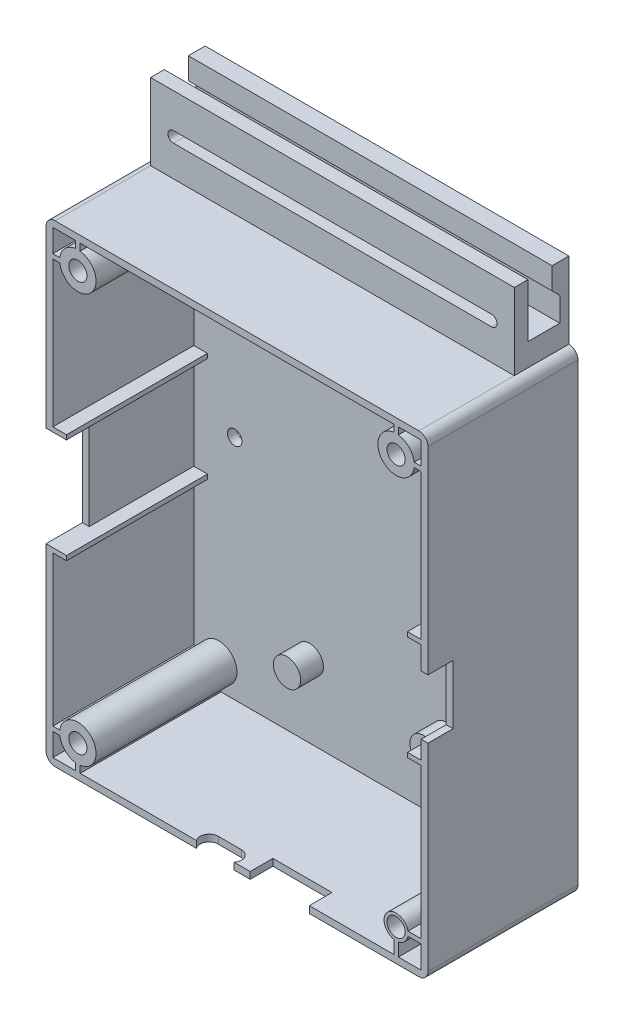
from build123d import *

# Parameters (mm, degrees)
SKETCH_2_R          = 2
EXTRUDE_1_DEPTH     = 31
EXTRUDE_1_2_DEPTH   = 31
EXTRUDE_1_3_DEPTH   = 31
EXTRUDE_1_4_DEPTH   = 31
SKETCH_3_W          = 81
SKETCH_3_H          = 101
EXTRUDE_2_DEPTH     = 31
EXTRUDE_3_DEPTH     = 2
CUT_EXTRUDE_1_REACH = 86
SKETCH_5_W          = 8
SKETCH_5_H          = 22
CUT_EXTRUDE_2_REACH = 86
SKETCH_6_W          = 5.5
SKETCH_6_H          = 13
CUT_EXTRUDE_3_REACH = 106
SKETCH_7_W          = 13
SKETCH_7_H          = 5
SKETCH_8_R          = 3
EXTRUDE_4_DEPTH     = 5
SKETCH_9_R          = 2
CUT_EXTRUDE_4_DEPTH = 5
SKETCH_10_W         = 80
SKETCH_10_H         = 12
EXTRUDE_5_DEPTH     = 5
SKETCH_11_W         = 3
SKETCH_11_H         = 11.8
EXTRUDE_6_DEPTH     = 80
CUT_EXTRUDE_5_DEPTH = 3
SKETCH_13_R         = 1.6
CUT_EXTRUDE_6_DEPTH = 3
SKETCH_14_W         = 31
SKETCH_14_H         = 1
EXTRUDE_7_DEPTH     = 3
SKETCH_15_W         = 31
SKETCH_15_H         = 1
EXTRUDE_8_DEPTH     = 3


with BuildPart() as part:
    # 草图2 → 凸台-拉伸1 (new body)
    with BuildSketch(Plane.XY):
        with BuildLine():
            Line((-38.968626967, -45.5), (-40.968626967, -45.5))
            Line((-40.968626967, -45.5), (-40.968626967, -44.5))
            Line((-40.968626967, -44.5), (-38.968626967, -44.5))
            ThreePointArc((-38.968626967, -44.5), (-32.171572875, -42.171572875), (-34.5, -48.968626967))
            Line((-34.5, -48.968626967), (-34.5, -50.968626967))
            Line((-34.5, -50.968626967), (-35.5, -50.968626967))
            Line((-35.5, -50.968626967), (-35.5, -48.968626967))
            ThreePointArc((-35.5, -48.968626967), (-37.828427125, -47.828427125), (-38.968626967, -45.5))
        make_face()
        with Locations((-35, -45)):
            Circle(SKETCH_2_R, mode=Mode.SUBTRACT)
    extrude(amount=-EXTRUDE_1_DEPTH)



with BuildPart() as body_2:
    # 草图2 → Extrude 1 2 (new body)
    with BuildSketch(Plane.XY):
        with BuildLine():
            Line((-35.5, 50.968626967), (-34.5, 50.968626967))
            Line((-34.5, 50.968626967), (-34.5, 48.968626967))
            ThreePointArc((-34.5, 48.968626967), (-32.171572875, 42.171572875), (-38.968626967, 44.5))
            Line((-38.968626967, 44.5), (-40.968626967, 44.5))
            Line((-40.968626967, 44.5), (-40.968626967, 45.5))
            Line((-40.968626967, 45.5), (-38.968626967, 45.5))
            ThreePointArc((-38.968626967, 45.5), (-37.828427125, 47.828427125), (-35.5, 48.968626967))
            Line((-35.5, 48.968626967), (-35.5, 50.968626967))
        make_face()
        with Locations((-35, 45)):
            Circle(SKETCH_2_R, mode=Mode.SUBTRACT)
    extrude(amount=-EXTRUDE_1_2_DEPTH)


with BuildPart() as body_3:
    # 草图2 → Extrude 1 3 (new body)
    with BuildSketch(Plane.XY):
        with BuildLine():
            Line((34.5, 50.968626967), (35.5, 50.968626967))
            Line((35.5, 50.968626967), (35.5, 48.968626967))
            ThreePointArc((35.5, 48.968626967), (37.828427125, 47.828427125), (38.968626967, 45.5))
            Line((38.968626967, 45.5), (40.968626967, 45.5))
            Line((40.968626967, 45.5), (40.968626967, 44.5))
            Line((40.968626967, 44.5), (38.968626967, 44.5))
            ThreePointArc((38.968626967, 44.5), (32.171572875, 42.171572875), (34.5, 48.968626967))
            Line((34.5, 48.968626967), (34.5, 50.968626967))
        make_face()
        with Locations((35, 45)):
            Circle(SKETCH_2_R, mode=Mode.SUBTRACT)
    extrude(amount=-EXTRUDE_1_3_DEPTH)


with BuildPart() as body_4:
    # 草图2 → Extrude 1 4 (new body)
    with BuildSketch(Plane.XY):
        with BuildLine():
            Line((40.602402736, -44.5), (40.602402736, -45.5))
            Line((40.602402736, -45.5), (37.602402736, -45.5))
            ThreePointArc((37.602402736, -45.5), (36.87383297, -46.87383297), (35.5, -47.602402736))
            Line((35.5, -47.602402736), (35.5, -50.602402736))
            Line((35.5, -50.602402736), (34.5, -50.602402736))
            Line((34.5, -50.602402736), (34.5, -47.602402736))
            ThreePointArc((34.5, -47.602402736), (33.12616703, -43.12616703), (37.602402736, -44.5))
            Line((37.602402736, -44.5), (40.602402736, -44.5))
        make_face()
        with Locations((35, -45)):
            Circle(SKETCH_2_R, mode=Mode.SUBTRACT)
    extrude(amount=-EXTRUDE_1_4_DEPTH)


with BuildPart() as body_5:
    # 草图3 → 凸台-拉伸2 (new body)
    with BuildSketch(Plane(origin=(0, 0, -31), x_dir=(-1, 0, 0), z_dir=(0, 0, -1))):
        with BuildLine():
            Line((-40, -52), (40, -52))
            ThreePointArc((40, -52), (41.414213562, -51.414213562), (42, -50))
            Line((42, -50), (42, 50))
            ThreePointArc((42, 50), (41.414213562, 51.414213562), (40, 52))
            Line((40, 52), (-40, 52))
            ThreePointArc((-40, 52), (-41.414213562, 51.414213562), (-42, 50))
            Line((-42, 50), (-42, -50))
            ThreePointArc((-42, -50), (-41.414213562, -51.414213562), (-40, -52))
        make_face()
        Rectangle(SKETCH_3_W, SKETCH_3_H, mode=Mode.SUBTRACT)
    extrude(amount=-EXTRUDE_2_DEPTH)


with BuildPart() as part_1:
    add(part.part)

    add(body_2.part)  # 凸台-拉伸3 merges body 2

    add(body_3.part)  # 凸台-拉伸3 merges body 3

    add(body_4.part)  # 凸台-拉伸3 merges body 4

    add(body_5.part)  # 凸台-拉伸3 merges body 5
    # 草图4 → 凸台-拉伸3 (add)
    with BuildSketch(Plane(origin=(0, 0, -31), x_dir=(-1, 0, 0), z_dir=(0, 0, -1))):
        with BuildLine():
            Line((40, 52), (-40, 52))
            ThreePointArc((-40, 52), (-41.414213562, 51.414213562), (-42, 50))
            Line((-42, 50), (-42, -50))
            ThreePointArc((-42, -50), (-41.414213562, -51.414213562), (-40, -52))
            Line((-40, -52), (40, -52))
            ThreePointArc((40, -52), (41.414213562, -51.414213562), (42, -50))
            Line((42, -50), (42, 50))
            ThreePointArc((42, 50), (41.414213562, 51.414213562), (40, 52))
        make_face()
    extrude(amount=EXTRUDE_3_DEPTH)

    # 草图5 → 切除-拉伸1 (cut, up to next)
    with BuildSketch(Plane.ZY.offset(42), mode=Mode.PRIVATE) as cut_extrude_1_sk1:
        with Locations((-4, 0.5)):
            Rectangle(SKETCH_5_W, SKETCH_5_H)
    cut_extrude_1_tool1 = extrude(cut_extrude_1_sk1.sketch, amount=-CUT_EXTRUDE_1_REACH, mode=Mode.PRIVATE) & part_1.part
    add(cut_extrude_1_tool1.solids().sort_by_distance((-42, 0.5, -4))[0], mode=Mode.SUBTRACT)

    # 草图6 → 切除-拉伸2 (cut, up to next)
    with BuildSketch(Plane(origin=(42, 0, 0), x_dir=(0, 0, -1), z_dir=(1, 0, 0)), mode=Mode.PRIVATE) as cut_extrude_2_sk1:
        with Locations((2.75, 0)):
            Rectangle(SKETCH_6_W, SKETCH_6_H)
    cut_extrude_2_tool1 = extrude(cut_extrude_2_sk1.sketch, amount=-CUT_EXTRUDE_2_REACH, mode=Mode.PRIVATE) & part_1.part
    add(cut_extrude_2_tool1.solids().sort_by_distance((42, 0, -2.75))[0], mode=Mode.SUBTRACT)

    # 草图7 → 切除-拉伸3 (cut, up to next)
    with BuildSketch(Plane.XZ.offset(52), mode=Mode.PRIVATE) as cut_extrude_3_sk1:
        with BuildLine():
            Line((-2.213, -3.2), (-7.313, -3.2))
            ThreePointArc((-7.313, -3.2), (-9.313, -1.2), (-7.313, 0.8))
            Line((-7.313, 0.8), (-2.213, 0.8))
            ThreePointArc((-2.213, 0.8), (-0.213, -1.2), (-2.213, -3.2))
        make_face()
    cut_extrude_3_tool1 = extrude(cut_extrude_3_sk1.sketch, amount=-CUT_EXTRUDE_3_REACH, mode=Mode.PRIVATE) & part_1.part
    add(cut_extrude_3_tool1.solids().sort_by_distance((-4.763, -52, -1.2))[0], mode=Mode.SUBTRACT)
    # 草图7 → 切除-拉伸3 (cut, up to next)
    with BuildSketch(Plane.XZ.offset(52), mode=Mode.PRIVATE) as cut_extrude_3_sk2:
        with Locations((9.397, -2.5)):
            Rectangle(SKETCH_7_W, SKETCH_7_H)
    cut_extrude_3_tool2 = extrude(cut_extrude_3_sk2.sketch, amount=-CUT_EXTRUDE_3_REACH, mode=Mode.PRIVATE) & part_1.part
    add(cut_extrude_3_tool2.solids().sort_by_distance((9.397, -52, -2.5))[0], mode=Mode.SUBTRACT)

    # 草图8 → 凸台-拉伸4 (add)
    with BuildSketch(Plane.XY.offset(-31)):
        with Locations((-15, -34.5)):
            Circle(SKETCH_8_R)
        with Locations((15, -34.5)):
            Circle(SKETCH_8_R)
        with Locations((-10, 46)):
            Circle(SKETCH_8_R)
        with Locations((10, 46)):
            Circle(SKETCH_8_R)
        with Locations((-10, 30)):
            Circle(SKETCH_8_R)
        with Locations((10, 30)):
            Circle(SKETCH_8_R)
    extrude(amount=EXTRUDE_4_DEPTH)

    # 草图9 → 切除-拉伸4 (cut)
    with BuildSketch(Plane(origin=(0, 0, -33), x_dir=(-1, 0, 0), z_dir=(0, 0, -1))):
        with Locations((-15, -34.5)):
            Circle(SKETCH_9_R)
        with Locations((15, -34.5)):
            Circle(SKETCH_9_R)
        with Locations((-10, 46)):
            Circle(SKETCH_9_R)
        with Locations((10, 46)):
            Circle(SKETCH_9_R)
        with Locations((10, 30)):
            Circle(SKETCH_9_R)
        with Locations((-10, 30)):
            Circle(SKETCH_9_R)
    extrude(amount=-CUT_EXTRUDE_4_DEPTH, mode=Mode.SUBTRACT)

    # 草图10 → 凸台-拉伸5 (add)
    with BuildSketch(Plane(origin=(0, 52, 0), x_dir=(1, 0, 0), z_dir=(0, 1, 0))):
        with Locations((0, 27)):
            Rectangle(SKETCH_10_W, SKETCH_10_H)
    extrude(amount=EXTRUDE_5_DEPTH)

    # 草图11 → 凸台-拉伸6 (add)
    with BuildSketch(Plane.ZY.offset(40)):
        Polygon((-33, 57), (-33, 68.8), (-29.3, 68.8), (-29.3, 64), (-31, 62.3), (-31, 57), align=None)
        with Locations((-22.5, 62.9)):
            Rectangle(SKETCH_11_W, SKETCH_11_H)
    extrude(amount=-EXTRUDE_6_DEPTH)

    # 草图12 → 切除-拉伸5 (cut)
    with BuildSketch(Plane(origin=(0, 0, -24), x_dir=(-1, 0, 0), z_dir=(0, 0, -1))):
        with BuildLine():
            Line((-35, 61.2), (35, 61.2))
            ThreePointArc((35, 61.2), (36.2, 60), (35, 58.8))
            Line((35, 58.8), (-35, 58.8))
            ThreePointArc((-35, 58.8), (-36.2, 60), (-35, 61.2))
        make_face()
    extrude(amount=-CUT_EXTRUDE_5_DEPTH, mode=Mode.SUBTRACT)

    # 草图13 → 切除-拉伸6 (cut, through all)
    with BuildSketch(Plane.XY.offset(-31)):
        with Locations((-31.5, -0.5)):
            Circle(SKETCH_13_R)
        with Locations((31.5, -0.5)):
            Circle(SKETCH_13_R)
    extrude(amount=-CUT_EXTRUDE_6_DEPTH, mode=Mode.SUBTRACT)

    # 草图14 → 凸台-拉伸7 (add)
    with BuildSketch(Plane(origin=(-40.5, 0, 0), x_dir=(0, 0, -1), z_dir=(1, 0, 0))):
        with Locations((15.5, 12)):
            Rectangle(SKETCH_14_W, SKETCH_14_H)
        with Locations((15.5, -11)):
            Rectangle(SKETCH_14_W, SKETCH_14_H)
    extrude(amount=EXTRUDE_7_DEPTH)

    # 草图15 → 凸台-拉伸8 (add)
    with BuildSketch(Plane.ZY.offset(-40.5)):
        with Locations((-15.5, 12)):
            Rectangle(SKETCH_15_W, SKETCH_15_H)
        with Locations((-15.5, -11)):
            Rectangle(SKETCH_15_W, SKETCH_15_H)
    extrude(amount=EXTRUDE_8_DEPTH)


solid = part_1.part
